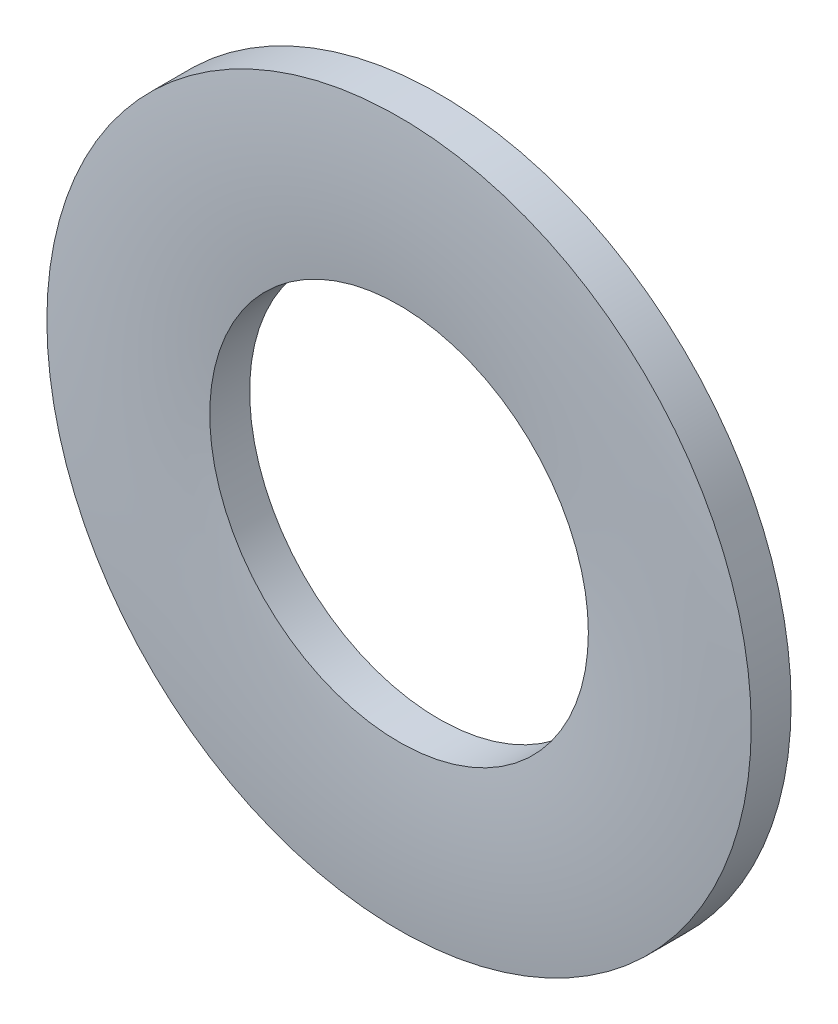
from build123d import *


with BuildPart() as part:
    # Sketch3 → Revolve1 (revolve)
    with BuildSketch(Plane(origin=(0, 0, 0), x_dir=(0, 0, -1), z_dir=(1, 0, 0))):
        with BuildLine():
            Line((0.25, 4), (-0.20315, 4))
            ThreePointArc((-0.20315, 4), (-0.25, 3.075), (-0.20315, 2.15))
            Line((-0.20315, 2.15), (0.25, 2.15))
            Line((0.25, 2.15), (0.25, 4))
        make_face()
    revolve(axis=Axis((0, 0, 0.25), (0, 0, -1)))


solid = part.part
